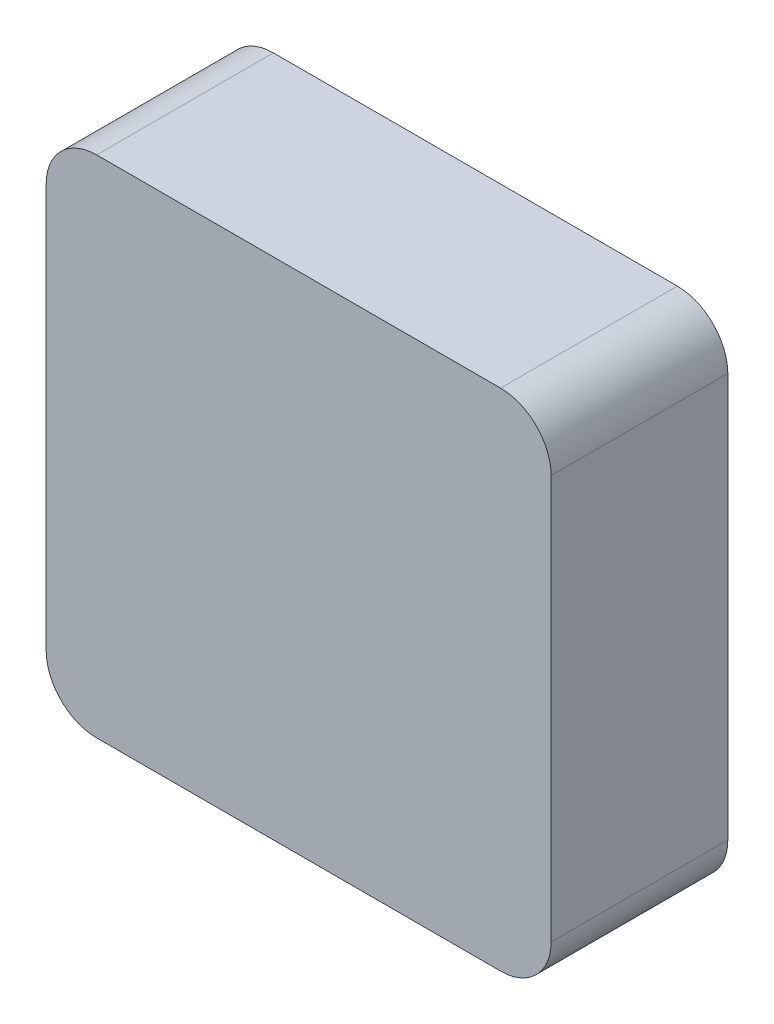
from build123d import *

# Parameters (mm, degrees)
SKETCH1_W           = 100
SKETCH1_H           = 100
BOSS_EXTRUDE1_DEPTH = 35
FILLET1_R           = 10
SKETCH2_W           = 9.403715906
SKETCH2_H           = 4.36940335
SKETCH2_W_2         = 10.971001891
SKETCH2_H_2         = 8.786300215
SKETCH2_W_3         = 11.255962979
SKETCH2_H_3         = 3.087078454
SKETCH2_W_4         = 10.021131597
SKETCH2_H_4         = 3.03958494
CUT_EXTRUDE1_DEPTH  = 5


with BuildPart() as part:
    # Sketch1 → Boss-Extrude1 (new body)
    with BuildSketch(Plane.XY):
        with Locations((50, 50)):
            Rectangle(SKETCH1_W, SKETCH1_H)
    extrude(amount=BOSS_EXTRUDE1_DEPTH)

    # Fillet1
    fillet1_edges = [part.edges().sort_by_distance(p)[0] for p in [
        (0, 100, 17.5),
        (100, 100, 17.5),
        (100, 0, 17.5),
        (0, 0, 17.5),
    ]]
    fillet(fillet1_edges, radius=FILLET1_R)

    # Sketch2 → Cut-Extrude1 (cut)
    with BuildSketch(Plane.XZ):
        with Locations((44.348271753, 16.241421861)):
            Rectangle(SKETCH2_W, SKETCH2_H)
        with Locations((24.709703434, 18.544857323)):
            Rectangle(SKETCH2_W_2, SKETCH2_H_2)
        with Locations((74.672880875, 15.885220501)):
            Rectangle(SKETCH2_W_3, SKETCH2_H_3)
        with Locations((60.377332957, 15.671499685)):
            Rectangle(SKETCH2_W_4, SKETCH2_H_4)
    extrude(amount=-CUT_EXTRUDE1_DEPTH, mode=Mode.SUBTRACT)


solid = part.part
